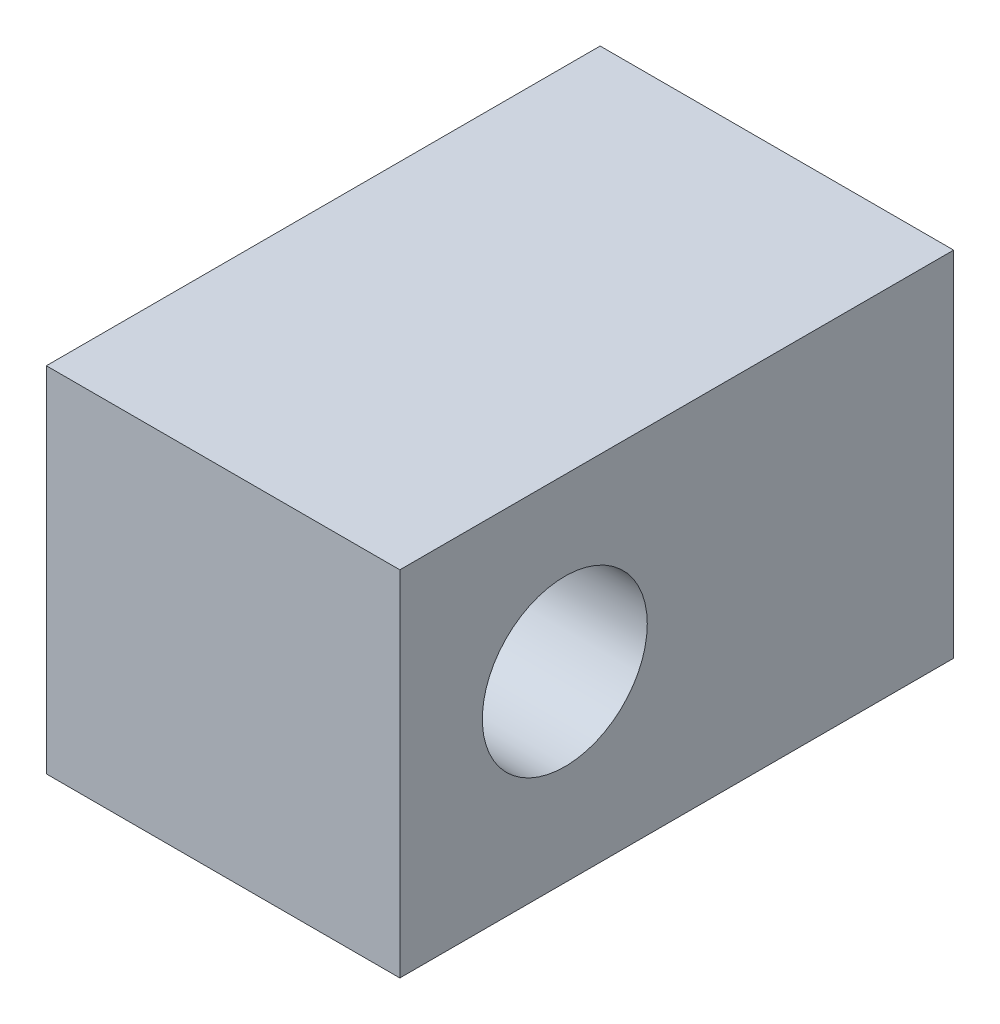
from build123d import *

# Parameters (mm, degrees)
SKETCH1_W           = 30
SKETCH1_H           = 30
BOSS_EXTRUDE1_DEPTH = 47
SKETCH2_R           = 7
CUT_EXTRUDE1_DEPTH  = 47


with BuildPart() as part:
    # Sketch1 → Boss-Extrude1 (new body)
    with BuildSketch(Plane.XY):
        Rectangle(SKETCH1_W, SKETCH1_H)
    extrude(amount=BOSS_EXTRUDE1_DEPTH)

    # Sketch2 → Cut-Extrude1 (cut)
    with BuildSketch(Plane(origin=(15, 0, 0), x_dir=(0, 0, -1), z_dir=(1, 0, 0))):
        with Locations((-33, 0.525821826)):
            Circle(SKETCH2_R)
    extrude(amount=-CUT_EXTRUDE1_DEPTH, mode=Mode.SUBTRACT)


solid = part.part
